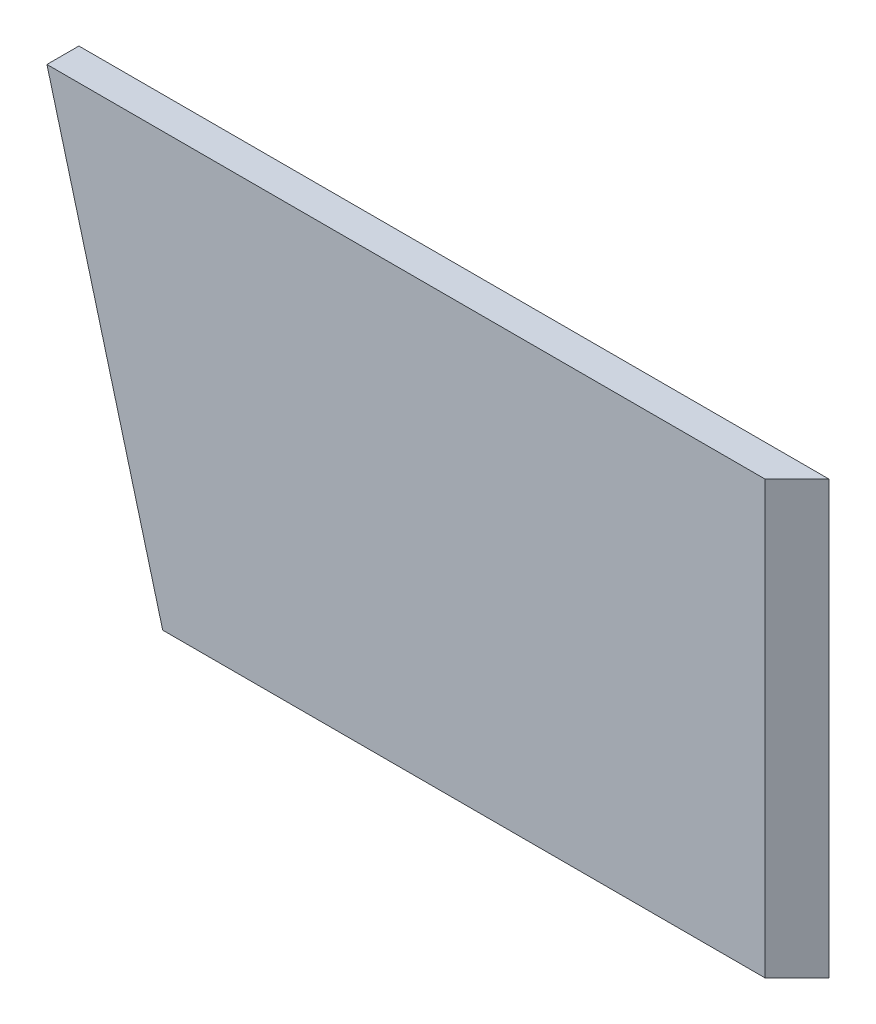
from build123d import *

# Parameters (mm, degrees)
SKETCH2_W           = 12.7
SKETCH2_H           = 171.7294
BOSS_EXTRUDE2_DEPTH = 381
CUT_EXTRUDE1_DEPTH  = 13.7
CUT_EXTRUDE2_DEPTH  = 172.7294


with BuildPart() as part:
    # Sketch2 → Boss-Extrude2 (new body)
    with BuildSketch(Plane.XY):
        with Locations((-6.35, 85.8647)):
            Rectangle(SKETCH2_W, SKETCH2_H)
    extrude(amount=BOSS_EXTRUDE2_DEPTH)

    # Sketch3 → Cut-Extrude1 (cut, through all)
    with BuildSketch(Plane(origin=(0, 0, 0), x_dir=(0, 0, -1), z_dir=(1, 0, 0))):
        Polygon((-252.1712, 0), (-298.185954047, 171.7294), (-381, 171.7294), (-381, 0), align=None)
    extrude(amount=-CUT_EXTRUDE1_DEPTH, mode=Mode.SUBTRACT)

    # Mirror2: part across plane


with BuildPart() as part_1:
    add(part.part)
    add(part.part.mirror(Plane(origin=(0, 0, 0), x_dir=(-0.707106781, 0, 0.707106781), z_dir=(0.707106781, 0, 0.707106781))))

    # Sketch4 → Cut-Extrude2 (cut, through all)
    with BuildSketch(Plane(origin=(0, 171.7294, 0), x_dir=(1, 0, 0), z_dir=(0, 1, 0))):
        Polygon((0, 0), (-12.7, -12.7), (-12.7, -298.185954047), (0, -298.185954047), align=None)
    extrude(amount=-CUT_EXTRUDE2_DEPTH, mode=Mode.SUBTRACT)


solid = part_1.part
